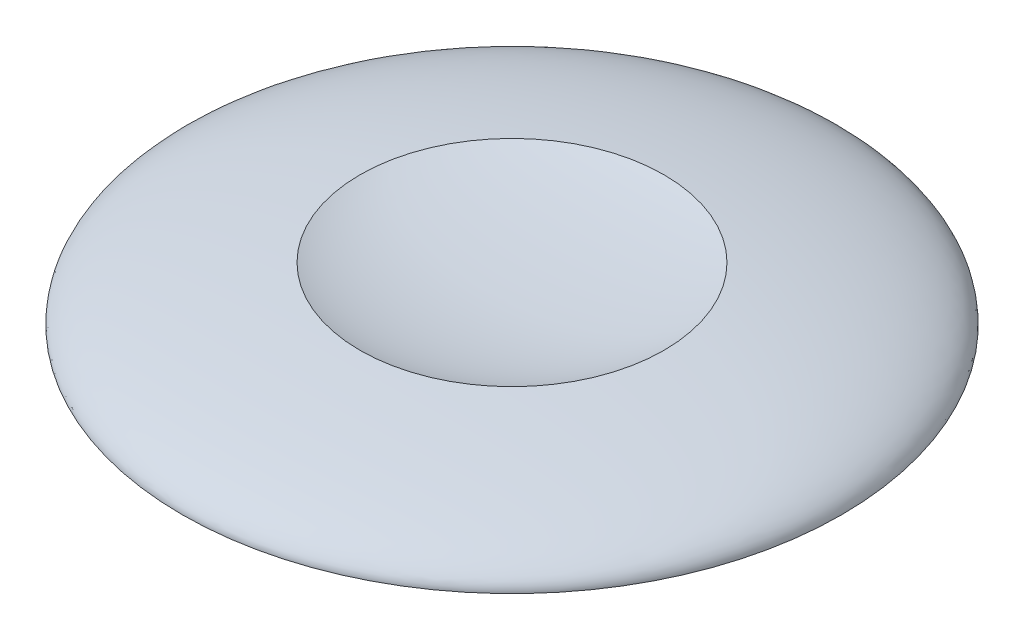
from build123d import *


with BuildPart() as part:
    # Sketch1 → Revolve1 (revolve)
    with BuildSketch(Plane(origin=(0, 0, 0), x_dir=(0, 0, -1), z_dir=(1, 0, 0))):
        with BuildLine():
            Line((1.7, 0), (5, 0))
            add(Edge.make_bspline(
                [(5, 0), (5, 0.55641384), (2.305550306, 0.81298186)],
                knots=[0, 0, 0, 1.09155054, 1.09155054, 1.09155054], degree=2, weights=[1, 0.85472512, 1]))
            add(Edge.make_bspline(
                [(0, 0.511437148), (1.515183128, 0.511437148), (2.305550306, 0.81298186)],
                knots=[4.71238898, 4.71238898, 4.71238898, 5.734423248, 5.734423248, 5.734423248], degree=2, weights=[1, 0.872247515, 1]))
            Line((0, 0.511437148), (0, -3))
            Line((0, -3), (0.6, -3))
            ThreePointArc((0.6, -3), (0.670710678, -2.970710678), (0.7, -2.9))
            Line((0.7, -2.9), (0.7, -0.1))
            Line((0.7, -0.1), (1.7, -0.1))
            Line((1.7, -0.1), (1.7, 0))
        make_face()
    revolve(axis=Axis((0, 0.511437148, 0), (0, -1, 0)))


solid = part.part
